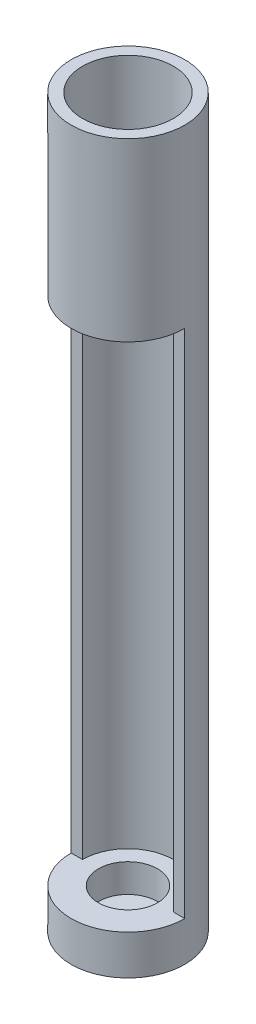
from build123d import *

# Parameters (mm, degrees)
SKETCH1_R           = 5
BOSS_EXTRUDE1_DEPTH = 3.5
SKETCH2_R           = 2.6
CUT_EXTRUDE1_DEPTH  = 2.5
BOSS_EXTRUDE2_DEPTH = 45
SKETCH4_R           = 5
SKETCH4_R_2         = 1.3
BOSS_EXTRUDE3_DEPTH = 3
SKETCH7_R           = 1
CUT_EXTRUDE2_DEPTH  = 2
CIRPATTERN1_COUNT   = 6
SKETCH8_R           = 5
SKETCH8_R_2         = 2.6
BOSS_EXTRUDE4_DEPTH = 2.5
SKETCH9_R           = 0.2
CUT_EXTRUDE3_DEPTH  = 50.012753442
CIRPATTERN2_COUNT   = 6
SKETCH10_R          = 5
SKETCH10_R_2        = 4
BOSS_EXTRUDE5_DEPTH = 10


with BuildPart() as part:
    # Sketch1 → Boss-Extrude1 (new body)
    with BuildSketch(Plane(origin=(0, 0, 0), x_dir=(1, 0, 0), z_dir=(0, 1, 0))):
        with Locations(Location((0, 0, 0), (0, 0, 270))):
            Circle(SKETCH1_R)
    extrude(amount=BOSS_EXTRUDE1_DEPTH)

    # Sketch2 → Cut-Extrude1 (cut)
    with BuildSketch(Plane(origin=(0, 3.5, 0), x_dir=(1, 0, 0), z_dir=(0, 1, 0))):
        with Locations(Location((0, 0, 0), (0, 0, 270))):
            Circle(SKETCH2_R)
    extrude(amount=-CUT_EXTRUDE1_DEPTH, mode=Mode.SUBTRACT)

    # Sketch3 → Boss-Extrude2 (add)
    with BuildSketch(Plane(origin=(0, 3.5, 0), x_dir=(1, 0, 0), z_dir=(0, 1, 0))):
        with BuildLine():
            Line((5, 0), (4, 0))
            ThreePointArc((4, 0), (0, 4), (-4, 0))
            Line((-4, 0), (-5, 0))
            ThreePointArc((-5, 0), (0, 5), (5, 0))
        make_face()
    extrude(amount=BOSS_EXTRUDE2_DEPTH)

    # Sketch4 → Boss-Extrude3 (add)
    with BuildSketch(Plane(origin=(0, 48.5, 0), x_dir=(1, 0, 0), z_dir=(0, 1, 0))):
        with Locations(Location((0, 0, 0), (0, 0, 270))):
            Circle(SKETCH4_R)
        with Locations(Location((0, 0, 0), (0, 0, 270))):
            Circle(SKETCH4_R_2, mode=Mode.SUBTRACT)
    extrude(amount=BOSS_EXTRUDE3_DEPTH)

    # Sketch7 → Cut-Extrude2 (cut)
    with BuildSketch(Plane.XZ.offset(-48.5)):
        with Locations(Location((0, 2.5, 0), (0, 0, 270))):
            Circle(SKETCH7_R)
    cut_extrude2 = extrude(amount=-CUT_EXTRUDE2_DEPTH, mode=Mode.SUBTRACT)

    # CirPattern1: Cut-Extrude2 ×6 about axis
    cirpattern1_axis = Axis((0, 0, 0), (0, 1, 0))
    for i in range(1, CIRPATTERN1_COUNT):
        add(cut_extrude2.rotate(cirpattern1_axis, i * 360 / CIRPATTERN1_COUNT), mode=Mode.SUBTRACT)

    # Sketch8 → Boss-Extrude4 (add)
    with BuildSketch(Plane(origin=(0, 51.5, 0), x_dir=(1, 0, 0), z_dir=(0, 1, 0))):
        with Locations(Location((0, 0, 0), (0, 0, 270))):
            Circle(SKETCH8_R)
        with Locations(Location((0, 0, 0), (0, 0, 270))):
            Circle(SKETCH8_R_2, mode=Mode.SUBTRACT)
    extrude(amount=BOSS_EXTRUDE4_DEPTH)

    # Sketch9 → Cut-Extrude3 (cut, through all)
    with BuildSketch(Plane.XZ.offset(-48.5)):
        with Locations(Location((0, 3, 0), (0, 0, 270))):
            Circle(SKETCH9_R)
    cut_extrude3 = extrude(amount=-CUT_EXTRUDE3_DEPTH, mode=Mode.SUBTRACT)

    # CirPattern2: Cut-Extrude3 ×6 about axis
    cirpattern2_axis = Axis((0, 0, 0), (0, 1, 0))
    for i in range(1, CIRPATTERN2_COUNT):
        add(cut_extrude3.rotate(cirpattern2_axis, i * 360 / CIRPATTERN2_COUNT), mode=Mode.SUBTRACT)

    # Sketch10 → Boss-Extrude5 (add)
    with BuildSketch(Plane(origin=(0, 54, 0), x_dir=(1, 0, 0), z_dir=(0, 1, 0))):
        with Locations(Location((0, 0, 0), (0, 0, 270))):
            Circle(SKETCH10_R)
        with Locations(Location((0, 0, 0), (0, 0, 270))):
            Circle(SKETCH10_R_2, mode=Mode.SUBTRACT)
    extrude(amount=BOSS_EXTRUDE5_DEPTH)


solid = part.part
